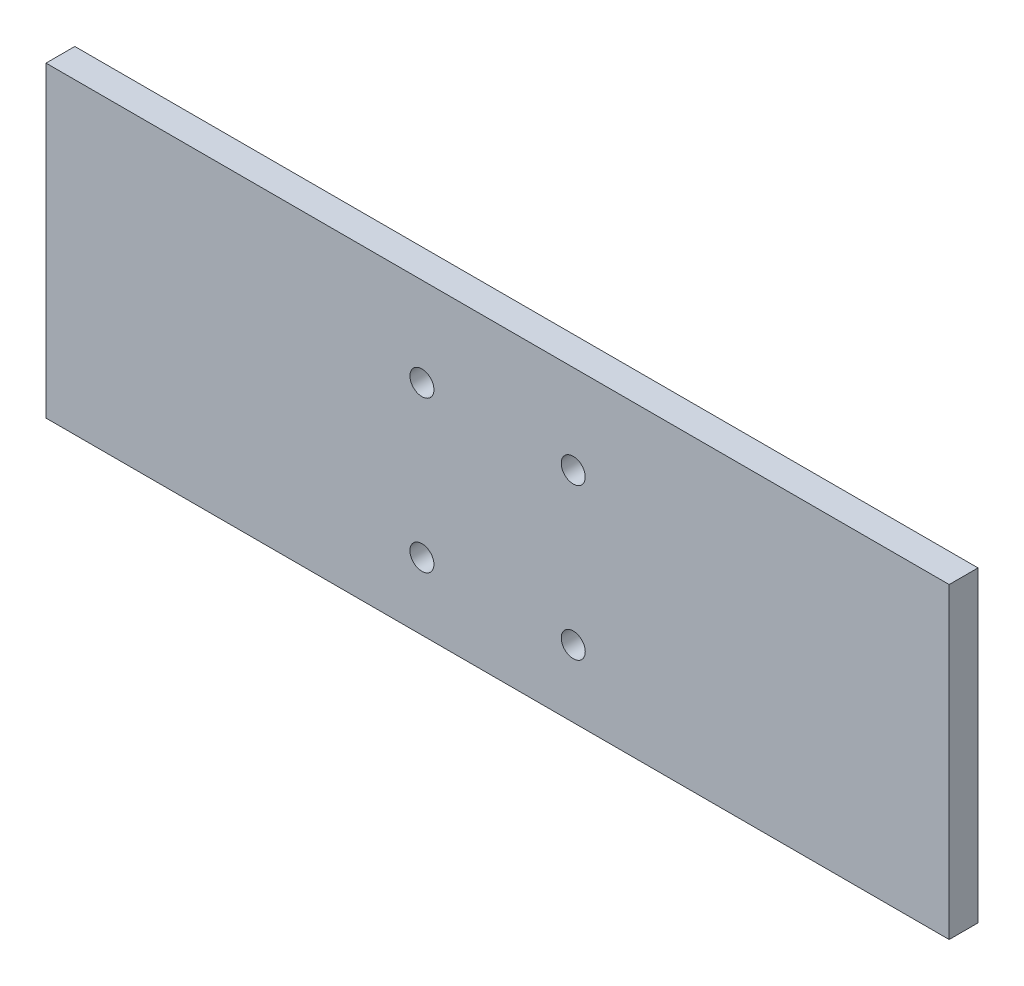
from build123d import *

# Parameters (mm, degrees)
SKETCH1_W           = 596.9
SKETCH1_H           = 203.2
BOSS_EXTRUDE1_DEPTH = 9.525
SKETCH2_R           = 7.9375
CUT_EXTRUDE1_DEPTH  = 20.05


with BuildPart() as part:
    # Sketch1 → Boss-Extrude1 (new body, symmetric)
    with BuildSketch(Plane.XY):
        Rectangle(SKETCH1_W, SKETCH1_H)
    extrude(amount=BOSS_EXTRUDE1_DEPTH, both=True)

    # Sketch2 → Cut-Extrude1 (cut, through all)
    with BuildSketch(Plane.XY.offset(9.525)):
        with Locations((-50, 42.85)):
            Circle(SKETCH2_R)
        with Locations((-50, -57.15)):
            Circle(SKETCH2_R)
        with Locations((50, 42.85)):
            Circle(SKETCH2_R)
        with Locations((50, -57.15)):
            Circle(SKETCH2_R)
    extrude(amount=-CUT_EXTRUDE1_DEPTH, mode=Mode.SUBTRACT)


solid = part.part
